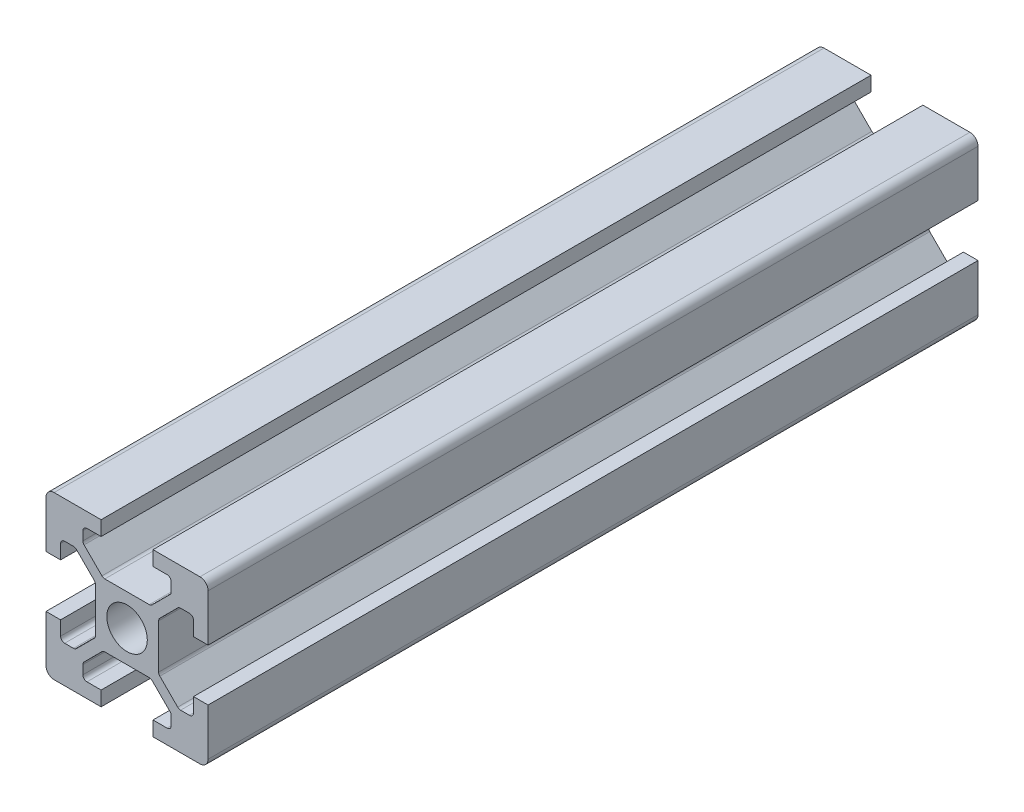
from build123d import *

# Parameters (mm, degrees)
SKETCH1_R           = 2.5
BOSS_EXTRUDE1_DEPTH = 95
FILLET1_R           = 1
FILLET2_R           = 0.5
FILLET3_R           = 0.5
FILLET4_R           = 0.5
FILLET5_R           = 0.5


with BuildPart() as part:
    # Sketch1 → Boss-Extrude1 (new body)
    with BuildSketch(Plane.XY):
        Polygon((13.2, 0), (13.2, 1.8), (15.45, 1.8), (15.45, 3.6), (12.95, 6.1), (7.05, 6.1), (4.55, 3.6), (4.55, 1.8), (6.8, 1.8), (6.8, 0), (0, 0), (0, 6.8), (1.8, 6.8), (1.8, 4.55), (3.6, 4.55), (6.1, 7.05), (6.1, 12.95), (3.6, 15.45), (1.8, 15.45), (1.8, 13.2), (0, 13.2), (0, 20), (6.8, 20), (6.8, 18.2), (4.55, 18.2), (4.55, 16.4), (7.05, 13.9), (12.95, 13.9), (15.45, 16.4), (15.45, 18.2), (13.2, 18.2), (13.2, 20), (20, 20), (20, 13.2), (18.2, 13.2), (18.2, 15.45), (16.4, 15.45), (13.9, 12.95), (13.9, 7.05), (16.4, 4.55), (18.2, 4.55), (18.2, 6.8), (20, 6.8), (20, 0), align=None)
        with Locations((10, 10)):
            Circle(SKETCH1_R, mode=Mode.SUBTRACT)
    extrude(amount=BOSS_EXTRUDE1_DEPTH)

    # Fillet1
    fillet1_edges = [part.edges().sort_by_distance(p)[0] for p in [
        (0, 0, 47.5),
        (0, 20, 47.5),
        (20, 20, 47.5),
        (20, 0, 47.5),
    ]]
    fillet(fillet1_edges, radius=FILLET1_R)

    # Fillet2
    fillet2_edges = [part.edges().sort_by_distance(p)[0] for p in [
        (4.55, 18.2, 47.5),
        (4.55, 16.4, 47.5),
        (7.05, 13.9, 47.5),
        (12.95, 13.9, 47.5),
        (15.45, 16.4, 47.5),
        (15.45, 18.2, 47.5),
    ]]
    fillet(fillet2_edges, radius=FILLET2_R)

    # Fillet3
    fillet3_edges = [part.edges().sort_by_distance(p)[0] for p in [
        (18.2, 15.45, 47.5),
        (16.4, 15.45, 47.5),
        (13.9, 12.95, 47.5),
        (13.9, 7.05, 47.5),
        (16.4, 4.55, 47.5),
        (18.2, 4.55, 47.5),
    ]]
    fillet(fillet3_edges, radius=FILLET3_R)

    # Fillet4
    fillet4_edges = [part.edges().sort_by_distance(p)[0] for p in [
        (1.8, 4.55, 47.5),
        (3.6, 4.55, 47.5),
        (6.1, 7.05, 47.5),
        (6.1, 12.95, 47.5),
        (3.6, 15.45, 47.5),
        (1.8, 15.45, 47.5),
    ]]
    fillet(fillet4_edges, radius=FILLET4_R)

    # Fillet5
    fillet5_edges = [part.edges().sort_by_distance(p)[0] for p in [
        (15.45, 1.8, 47.5),
        (15.45, 3.6, 47.5),
        (12.95, 6.1, 47.5),
        (7.05, 6.1, 47.5),
        (4.55, 3.6, 47.5),
        (4.55, 1.8, 47.5),
    ]]
    fillet(fillet5_edges, radius=FILLET5_R)


solid = part.part
